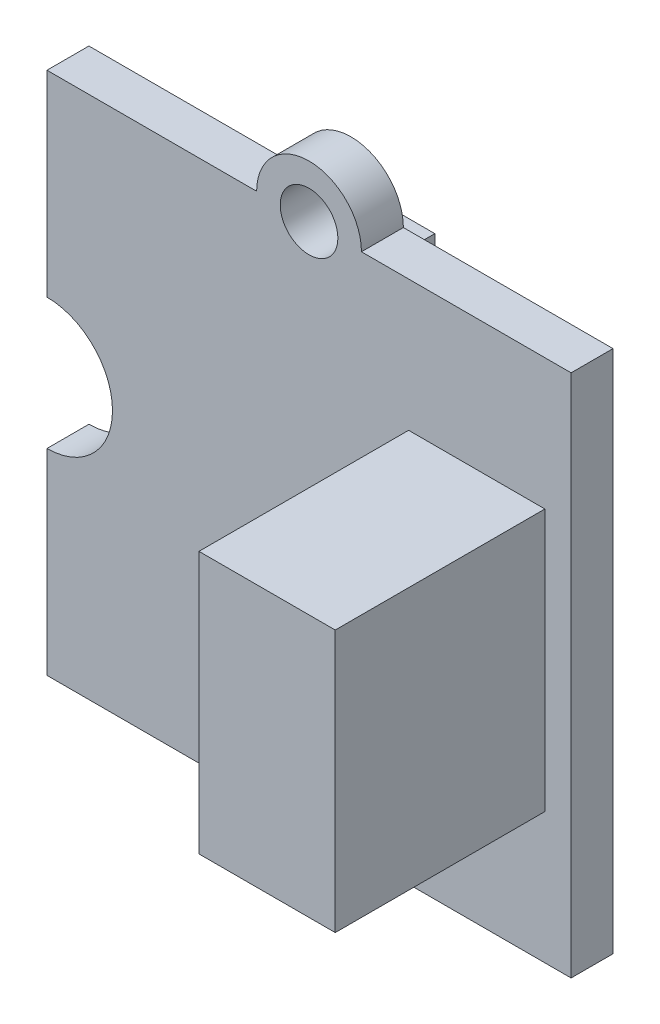
from build123d import *

# Parameters (mm, degrees)
SKETCH_1_R      = 1.1
EXTRUDE_1_DEPTH = 1.6
SKETCH_2_W      = 4.6
SKETCH_2_H      = 8.8
EXTRUDE_2_DEPTH = 6
SKETCH_3_W      = 5.2
SKETCH_3_H      = 10
EXTRUDE_3_DEPTH = 8


with BuildPart() as part:
    # ｽｹｯﾁ1 → ﾎﾞｽ - 押し出し1 (new body)
    with BuildSketch(Plane(origin=(0, 0, 0), x_dir=(0, 1, 0), z_dir=(0, 0, 1))):
        with BuildLine():
            Line((0, 8), (0, 0))
            Line((0, 0), (20, 0))
            Line((20, 0), (20, 8))
            ThreePointArc((20, 8), (22, 10), (20, 12))
            Line((20, 12), (20, 20))
            Line((20, 20), (12.5, 20))
            ThreePointArc((12.5, 20), (10, 17.5), (7.5, 20))
            Line((7.5, 20), (0, 20))
            Line((0, 20), (0, 12))
            ThreePointArc((0, 12), (-2, 10), (0, 8))
        make_face()
        with Locations((20, 10)):
            Circle(SKETCH_1_R, mode=Mode.SUBTRACT)
        with Locations((0, 10)):
            Circle(SKETCH_1_R, mode=Mode.SUBTRACT)
    extrude(amount=EXTRUDE_1_DEPTH)

    # ｽｹｯﾁ2 → ﾎﾞｽ - 押し出し2 (add)
    with BuildSketch(Plane(origin=(0, 0, 0), x_dir=(1, 0, 0), z_dir=(0, 0, -1))):
        with Locations((-15.1, -10)):
            Rectangle(SKETCH_2_W, SKETCH_2_H)
    extrude(amount=EXTRUDE_2_DEPTH)

    # ｽｹｯﾁ3 → ﾎﾞｽ - 押し出し3 (add)
    with BuildSketch(Plane.XY.offset(1.6)):
        with Locations((-3.6, 10)):
            Rectangle(SKETCH_3_W, SKETCH_3_H)
    extrude(amount=EXTRUDE_3_DEPTH)


solid = part.part
